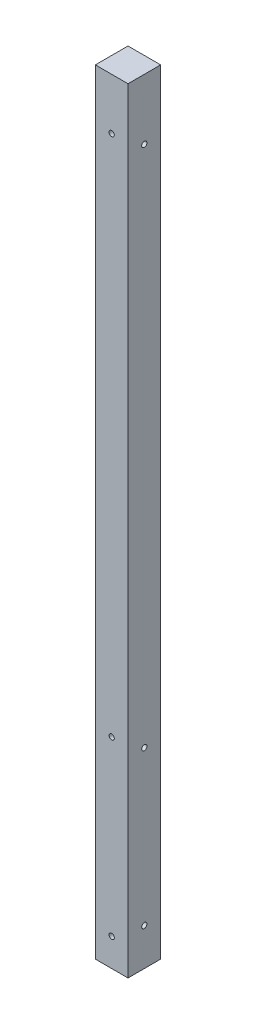
from build123d import *

# Parameters (mm, degrees)
SKETCH1_W           = 88.9
SKETCH1_H           = 88.9
BOSS_EXTRUDE2_DEPTH = 2108.2
SKETCH2_R           = 7.14375
CUT_EXTRUDE1_DEPTH  = 89.9
SKETCH3_R           = 7.14375
CUT_EXTRUDE2_DEPTH  = 89.9


with BuildPart() as part:
    # Sketch1 → Boss-Extrude2 (new body)
    with BuildSketch(Plane(origin=(0, 0, 0), x_dir=(1, 0, 0), z_dir=(0, 1, 0))):
        Rectangle(SKETCH1_W, SKETCH1_H)
    extrude(amount=BOSS_EXTRUDE2_DEPTH)

    # Sketch2 → Cut-Extrude1 (cut, through all)
    with BuildSketch(Plane.XY.offset(44.45)):
        with Locations((0, 76.2)):
            Circle(SKETCH2_R)
        with Locations((0, 546.1)):
            Circle(SKETCH2_R)
        with Locations((0, 1968.5)):
            Circle(SKETCH2_R)
    extrude(amount=-CUT_EXTRUDE1_DEPTH, mode=Mode.SUBTRACT)

    # Sketch3 → Cut-Extrude2 (cut, through all)
    with BuildSketch(Plane(origin=(44.45, 0, 0), x_dir=(0, 0, -1), z_dir=(1, 0, 0))):
        with Locations((0, 101.6)):
            Circle(SKETCH3_R)
        with Locations((0, 520.7)):
            Circle(SKETCH3_R)
        with Locations((0, 1943.1)):
            Circle(SKETCH3_R)
    extrude(amount=-CUT_EXTRUDE2_DEPTH, mode=Mode.SUBTRACT)


solid = part.part
